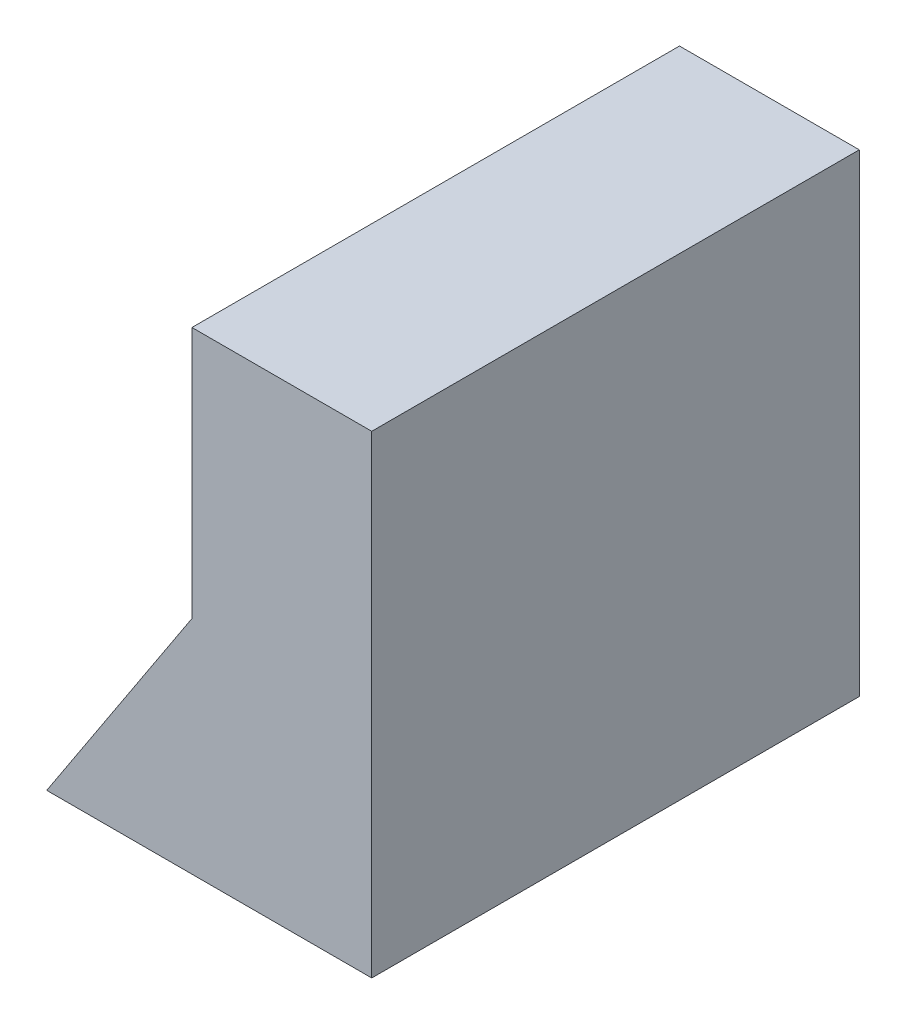
from build123d import *

# Parameters (mm, degrees)
BOSS_EXTRUDE1_DEPTH = 9


with BuildPart() as part:
    # Sketch1 → Boss-Extrude1 (new body, symmetric)
    with BuildSketch(Plane.XY):
        Polygon((18.96606777, 20.30441203), (24.327951182, 28.478887052), (24.327951182, 37.78550185), (30.96606777, 37.78550185), (30.96606777, 28.478887052), (30.96606777, 20.30441203), align=None)
    extrude(amount=BOSS_EXTRUDE1_DEPTH, both=True)


solid = part.part
